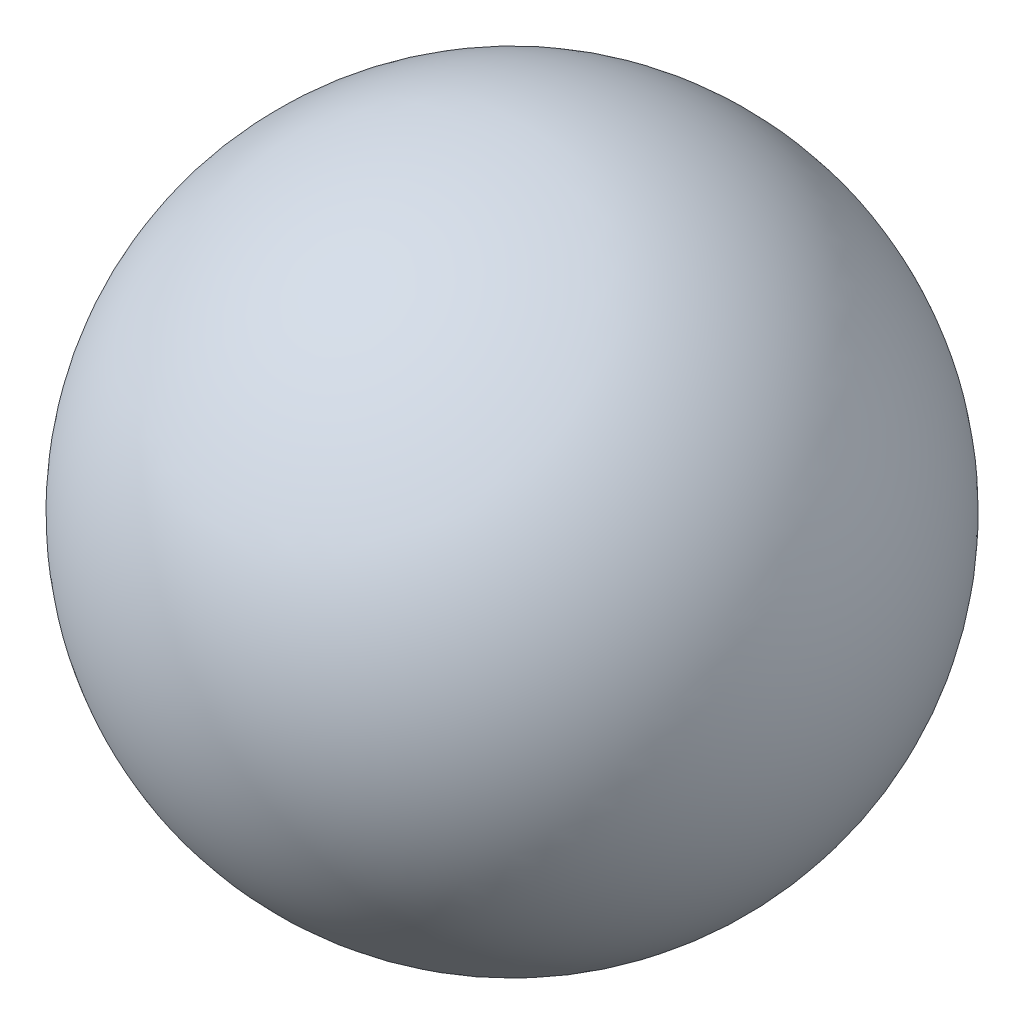
from build123d import *


with BuildPart() as part:
    # Sketch2 → Revolve3 (revolve)
    with BuildSketch(Plane(origin=(0, 0, 0), x_dir=(1, 0, 0), z_dir=(0, 1, 0))):
        with BuildLine():
            Line((0, -1.5875), (0, 1.5875))
            ThreePointArc((0, 1.5875), (1.5875, 0), (0, -1.5875))
        make_face()
    revolve(axis=Axis((0, 0, 1.5875), (0, 0, -1)))


solid = part.part
